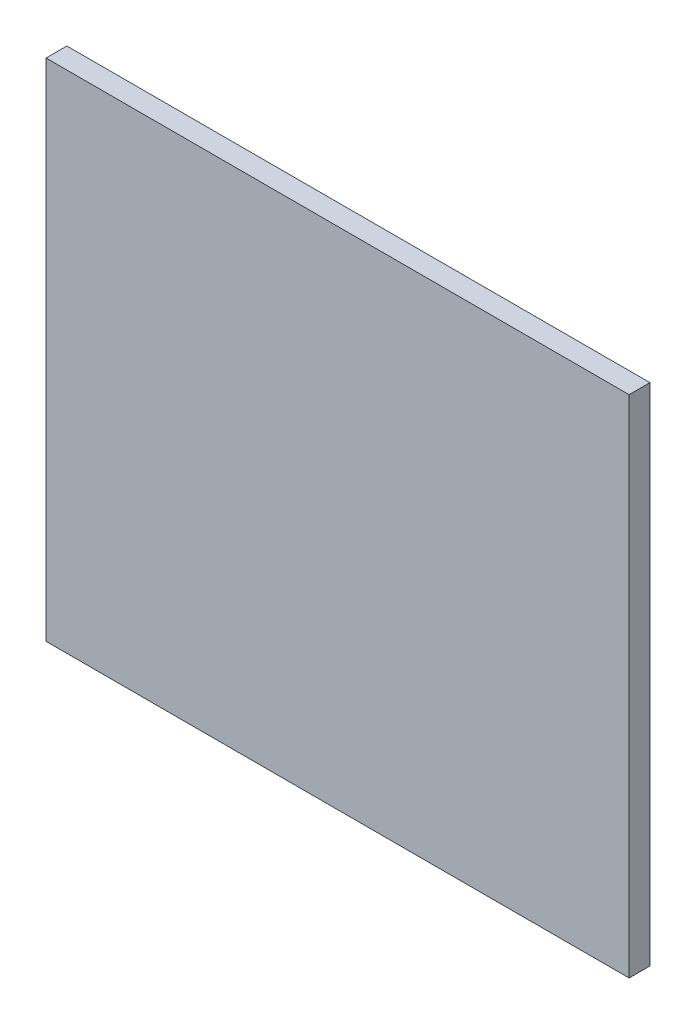
from build123d import *

# Parameters (mm, degrees)
SKETCH1_W           = 355.6
SKETCH1_H           = 308.102
BOSS_EXTRUDE1_DEPTH = 12.7


with BuildPart() as part:
    # Sketch1 → Boss-Extrude1 (new body)
    with BuildSketch(Plane.XY):
        with Locations((177.8, 154.051)):
            Rectangle(SKETCH1_W, SKETCH1_H)
    extrude(amount=BOSS_EXTRUDE1_DEPTH)


solid = part.part
